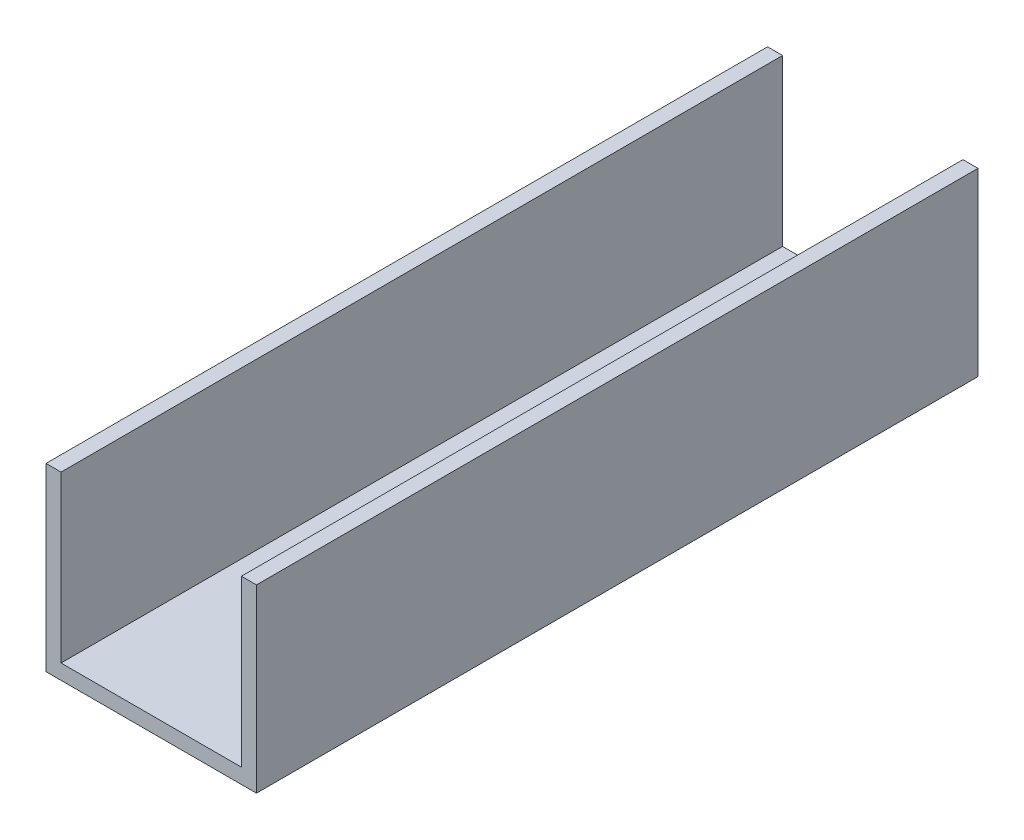
from build123d import *

# Parameters (mm, degrees)
BOSS_EXTRUDE1_DEPTH = 152.4


with BuildPart() as part:
    # Sketch1 → Boss-Extrude1 (new body)
    with BuildSketch(Plane.XY):
        Polygon((19.05, 38.1), (22.225, 38.1), (22.225, 0), (-22.225, 0), (-22.225, 38.1), (-19.05, 38.1), (-19.05, 3.175), (19.05, 3.175), align=None)
    extrude(amount=-BOSS_EXTRUDE1_DEPTH)


solid = part.part
